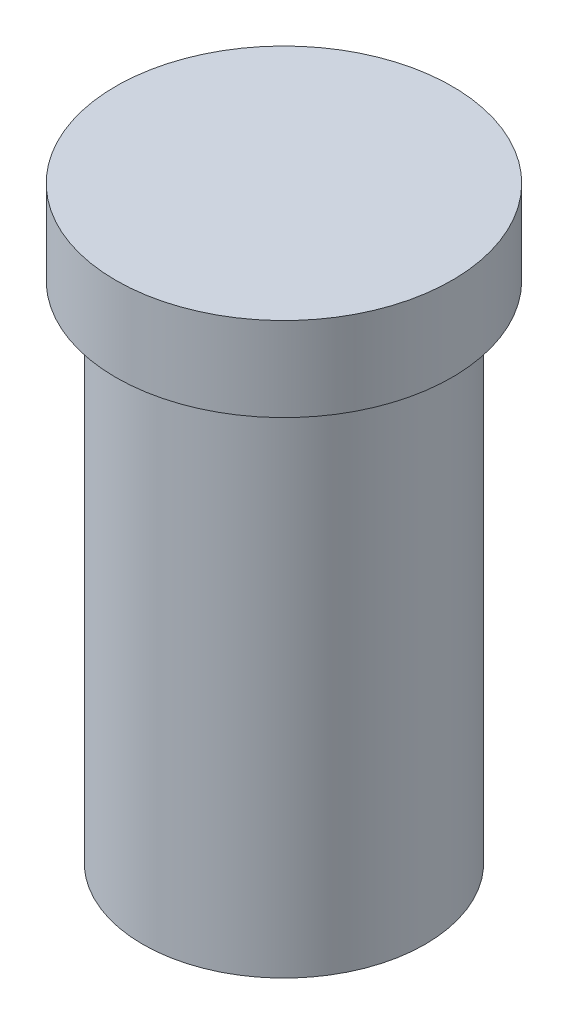
from build123d import *


with BuildPart() as part:
    # Sketch1 → Revolve1 (revolve)
    with BuildSketch(Plane.XY):
        Polygon((-3.175, -18.415), (-3.175, -22.225), (-5.334, -22.225), (-5.334, -3.175), (-6.35, -3.175), (-6.35, 0), (0, 0), (0, -18.415), align=None)
    revolve(axis=Axis((0, 0, 0), (0, -1, 0)))


solid = part.part
